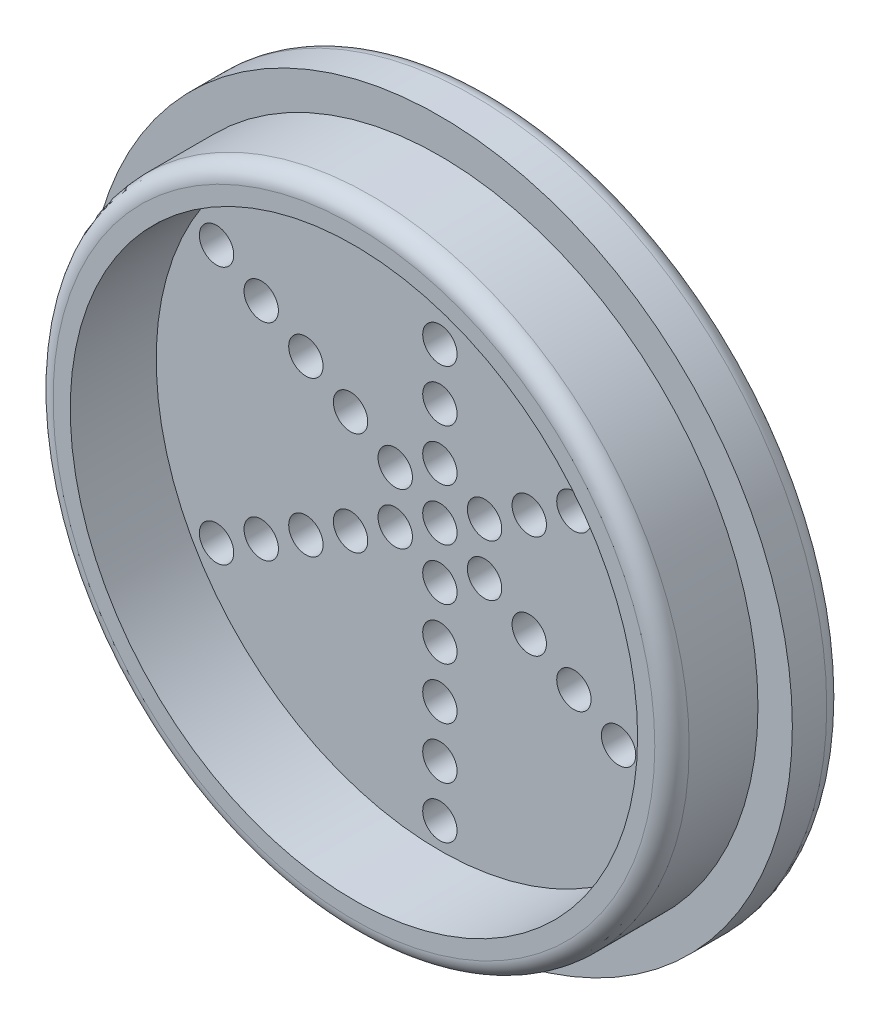
from build123d import *

# Parameters (mm, degrees)
SKETCH2_R                      = 20.5
BOSS_EXTRUDE1_DEPTH            = 3
SKETCH3_R                      = 18.5
BOSS_EXTRUDE2_DEPTH            = 5
SKETCH4_R                      = 16.5
CUT_EXTRUDE1_DEPTH             = 5
FILLET1_R                      = 1
FILLET2_R                      = 1
SKETCH9_R                      = 1
CUT_EXTRUDE2_DEPTH             = 3
F_2_0MM_DOWEL_HOLE4_AT_2_COUNT = 2
F_2_0MM_DOWEL_HOLE4_AT_2_PITCH = 3
F_2_0MM_DOWEL_HOLE4_AT_3_COUNT = 2
F_2_0MM_DOWEL_HOLE4_AT_3_PITCH = 6
F_2_0MM_DOWEL_HOLE4_AT_4_COUNT = 2
F_2_0MM_DOWEL_HOLE4_AT_4_PITCH = 9
F_2_0MM_DOWEL_HOLE4_AT_5_COUNT = 2
F_2_0MM_DOWEL_HOLE4_AT_5_PITCH = 12
CIRPATTERN1_COUNT              = 6


with BuildPart() as part:
    # Sketch2 → Boss-Extrude1 (new body)
    with BuildSketch(Plane.XY):
        Circle(SKETCH2_R)
    extrude(amount=BOSS_EXTRUDE1_DEPTH)

    # Sketch3 → Boss-Extrude2 (add)
    with BuildSketch(Plane.XY.offset(3)):
        Circle(SKETCH3_R)
    extrude(amount=BOSS_EXTRUDE2_DEPTH)

    # Sketch4 → Cut-Extrude1 (cut)
    with BuildSketch(Plane.XY.offset(8)):
        Circle(SKETCH4_R)
    extrude(amount=-CUT_EXTRUDE1_DEPTH, mode=Mode.SUBTRACT)

    # Fillet1
    fillet1_edges = [part.edges().sort_by_distance(p)[0] for p in [
        (-18.5, 0, 8),
    ]]
    fillet(fillet1_edges, radius=FILLET1_R)

    # Fillet2
    fillet2_edges = [part.edges().sort_by_distance(p)[0] for p in [
        (-20.5, 0, 0),
    ]]
    fillet(fillet2_edges, radius=FILLET2_R)

    # Sketch9 → Cut-Extrude2 (cut)
    with BuildSketch(Plane(origin=(0, 0, 0), x_dir=(-1, 0, 0), z_dir=(0, 0, -1))):
        Circle(SKETCH9_R)
    extrude(amount=-CUT_EXTRUDE2_DEPTH, mode=Mode.SUBTRACT)

    # Sketch12 → Ø2.0mm Dowel Hole4 (revolve, cut)
    with BuildSketch(Plane(origin=(0, 3, 0), x_dir=(0, 1, 0), z_dir=(1, 0, 0))):
        Polygon((0, 0), (0, 100.600860619), (1, 100), (1, 0), align=None)
    f_2_0mm_dowel_hole4 = revolve(axis=Axis((0, 3, -6.35), (0, 0, 1)), mode=Mode.SUBTRACT)

    # Ø2.0mm Dowel Hole4 at 2: Ø2.0mm Dowel Hole4 ×2
    with Locations(*[(0, i * F_2_0MM_DOWEL_HOLE4_AT_2_PITCH, 0) for i in range(1, F_2_0MM_DOWEL_HOLE4_AT_2_COUNT)]):
        add(f_2_0mm_dowel_hole4, mode=Mode.SUBTRACT)

    # Ø2.0mm Dowel Hole4 at 3: Ø2.0mm Dowel Hole4 ×2
    with Locations(*[(0, i * F_2_0MM_DOWEL_HOLE4_AT_3_PITCH, 0) for i in range(1, F_2_0MM_DOWEL_HOLE4_AT_3_COUNT)]):
        add(f_2_0mm_dowel_hole4, mode=Mode.SUBTRACT)

    # Ø2.0mm Dowel Hole4 at 4: Ø2.0mm Dowel Hole4 ×2
    with Locations(*[(0, i * F_2_0MM_DOWEL_HOLE4_AT_4_PITCH, 0) for i in range(1, F_2_0MM_DOWEL_HOLE4_AT_4_COUNT)]):
        add(f_2_0mm_dowel_hole4, mode=Mode.SUBTRACT)

    # Ø2.0mm Dowel Hole4 at 5: Ø2.0mm Dowel Hole4 ×2
    with Locations(*[(0, i * F_2_0MM_DOWEL_HOLE4_AT_5_PITCH, 0) for i in range(1, F_2_0MM_DOWEL_HOLE4_AT_5_COUNT)]):
        add(f_2_0mm_dowel_hole4, mode=Mode.SUBTRACT)

    # CirPattern1: Ø2.0mm Dowel Hole4 ×6 about axis
    cirpattern1_axis = Axis((0, 0, 0), (0, 0, 1))
    for i in range(1, CIRPATTERN1_COUNT):
        add(f_2_0mm_dowel_hole4.rotate(cirpattern1_axis, i * 360 / CIRPATTERN1_COUNT), mode=Mode.SUBTRACT)

    # CirPattern1 copy 1 sketch → CirPattern1 copy 1 (revolve, cut)
    with BuildSketch(Plane(origin=(-5.196152423, 3, 0), x_dir=(-0.866025404, 0.5, 0), z_dir=(0.5, 0.866025404, 0))):
        Polygon((0, 0), (0, 100.600860619), (1, 100), (1, 0), align=None)
    revolve(axis=Axis((-5.196152423, 3, -6.35), (0, 0, 1)), mode=Mode.SUBTRACT)

    # CirPattern1 copy 2 sketch → CirPattern1 copy 2 (revolve, cut)
    with BuildSketch(Plane(origin=(-5.196152423, -3, 0), x_dir=(-0.866025404, -0.5, 0), z_dir=(-0.5, 0.866025404, 0))):
        Polygon((0, 0), (0, 100.600860619), (1, 100), (1, 0), align=None)
    revolve(axis=Axis((-5.196152423, -3, -6.35), (0, 0, 1)), mode=Mode.SUBTRACT)

    # CirPattern1 copy 3 sketch → CirPattern1 copy 3 (revolve, cut)
    with BuildSketch(Plane(origin=(0, -6, 0), x_dir=(0, -1, 0), z_dir=(-1, 0, 0))):
        Polygon((0, 0), (0, 100.600860619), (1, 100), (1, 0), align=None)
    revolve(axis=Axis((0, -6, -6.35), (0, 0, 1)), mode=Mode.SUBTRACT)

    # CirPattern1 copy 4 sketch → CirPattern1 copy 4 (revolve, cut)
    with BuildSketch(Plane(origin=(5.196152423, -3, 0), x_dir=(0.866025404, -0.5, 0), z_dir=(-0.5, -0.866025404, 0))):
        Polygon((0, 0), (0, 100.600860619), (1, 100), (1, 0), align=None)
    revolve(axis=Axis((5.196152423, -3, -6.35), (0, 0, 1)), mode=Mode.SUBTRACT)

    # CirPattern1 copy 5 sketch → CirPattern1 copy 5 (revolve, cut)
    with BuildSketch(Plane(origin=(5.196152423, 3, 0), x_dir=(0.866025404, 0.5, 0), z_dir=(0.5, -0.866025404, 0))):
        Polygon((0, 0), (0, 100.600860619), (1, 100), (1, 0), align=None)
    revolve(axis=Axis((5.196152423, 3, -6.35), (0, 0, 1)), mode=Mode.SUBTRACT)

    # CirPattern1 copy 6 sketch → CirPattern1 copy 6 (revolve, cut)
    with BuildSketch(Plane(origin=(-7.794228634, 4.5, 0), x_dir=(-0.866025404, 0.5, 0), z_dir=(0.5, 0.866025404, 0))):
        Polygon((0, 0), (0, 100.600860619), (1, 100), (1, 0), align=None)
    revolve(axis=Axis((-7.794228634, 4.5, -6.35), (0, 0, 1)), mode=Mode.SUBTRACT)

    # CirPattern1 copy 7 sketch → CirPattern1 copy 7 (revolve, cut)
    with BuildSketch(Plane(origin=(-7.794228634, -4.5, 0), x_dir=(-0.866025404, -0.5, 0), z_dir=(-0.5, 0.866025404, 0))):
        Polygon((0, 0), (0, 100.600860619), (1, 100), (1, 0), align=None)
    revolve(axis=Axis((-7.794228634, -4.5, -6.35), (0, 0, 1)), mode=Mode.SUBTRACT)

    # CirPattern1 copy 8 sketch → CirPattern1 copy 8 (revolve, cut)
    with BuildSketch(Plane(origin=(0, -9, 0), x_dir=(0, -1, 0), z_dir=(-1, 0, 0))):
        Polygon((0, 0), (0, 100.600860619), (1, 100), (1, 0), align=None)
    revolve(axis=Axis((0, -9, -6.35), (0, 0, 1)), mode=Mode.SUBTRACT)

    # CirPattern1 copy 9 sketch → CirPattern1 copy 9 (revolve, cut)
    with BuildSketch(Plane(origin=(7.794228634, -4.5, 0), x_dir=(0.866025404, -0.5, 0), z_dir=(-0.5, -0.866025404, 0))):
        Polygon((0, 0), (0, 100.600860619), (1, 100), (1, 0), align=None)
    revolve(axis=Axis((7.794228634, -4.5, -6.35), (0, 0, 1)), mode=Mode.SUBTRACT)

    # CirPattern1 copy 10 sketch → CirPattern1 copy 10 (revolve, cut)
    with BuildSketch(Plane(origin=(7.794228634, 4.5, 0), x_dir=(0.866025404, 0.5, 0), z_dir=(0.5, -0.866025404, 0))):
        Polygon((0, 0), (0, 100.600860619), (1, 100), (1, 0), align=None)
    revolve(axis=Axis((7.794228634, 4.5, -6.35), (0, 0, 1)), mode=Mode.SUBTRACT)

    # CirPattern1 copy 11 sketch → CirPattern1 copy 11 (revolve, cut)
    with BuildSketch(Plane(origin=(-10.392304845, 6, 0), x_dir=(-0.866025404, 0.5, 0), z_dir=(0.5, 0.866025404, 0))):
        Polygon((0, 0), (0, 100.600860619), (1, 100), (1, 0), align=None)
    revolve(axis=Axis((-10.392304845, 6, -6.35), (0, 0, 1)), mode=Mode.SUBTRACT)

    # CirPattern1 copy 12 sketch → CirPattern1 copy 12 (revolve, cut)
    with BuildSketch(Plane(origin=(-10.392304845, -6, 0), x_dir=(-0.866025404, -0.5, 0), z_dir=(-0.5, 0.866025404, 0))):
        Polygon((0, 0), (0, 100.600860619), (1, 100), (1, 0), align=None)
    revolve(axis=Axis((-10.392304845, -6, -6.35), (0, 0, 1)), mode=Mode.SUBTRACT)

    # CirPattern1 copy 13 sketch → CirPattern1 copy 13 (revolve, cut)
    with BuildSketch(Plane(origin=(0, -12, 0), x_dir=(0, -1, 0), z_dir=(-1, 0, 0))):
        Polygon((0, 0), (0, 100.600860619), (1, 100), (1, 0), align=None)
    revolve(axis=Axis((0, -12, -6.35), (0, 0, 1)), mode=Mode.SUBTRACT)

    # CirPattern1 copy 14 sketch → CirPattern1 copy 14 (revolve, cut)
    with BuildSketch(Plane(origin=(10.392304845, -6, 0), x_dir=(0.866025404, -0.5, 0), z_dir=(-0.5, -0.866025404, 0))):
        Polygon((0, 0), (0, 100.600860619), (1, 100), (1, 0), align=None)
    revolve(axis=Axis((10.392304845, -6, -6.35), (0, 0, 1)), mode=Mode.SUBTRACT)

    # CirPattern1 copy 15 sketch → CirPattern1 copy 15 (revolve, cut)
    with BuildSketch(Plane(origin=(10.392304845, 6, 0), x_dir=(0.866025404, 0.5, 0), z_dir=(0.5, -0.866025404, 0))):
        Polygon((0, 0), (0, 100.600860619), (1, 100), (1, 0), align=None)
    revolve(axis=Axis((10.392304845, 6, -6.35), (0, 0, 1)), mode=Mode.SUBTRACT)

    # CirPattern1 copy 16 sketch → CirPattern1 copy 16 (revolve, cut)
    with BuildSketch(Plane(origin=(-12.990381057, 7.5, 0), x_dir=(-0.866025404, 0.5, 0), z_dir=(0.5, 0.866025404, 0))):
        Polygon((0, 0), (0, 100.600860619), (1, 100), (1, 0), align=None)
    revolve(axis=Axis((-12.990381057, 7.5, -6.35), (0, 0, 1)), mode=Mode.SUBTRACT)

    # CirPattern1 copy 17 sketch → CirPattern1 copy 17 (revolve, cut)
    with BuildSketch(Plane(origin=(-12.990381057, -7.5, 0), x_dir=(-0.866025404, -0.5, 0), z_dir=(-0.5, 0.866025404, 0))):
        Polygon((0, 0), (0, 100.600860619), (1, 100), (1, 0), align=None)
    revolve(axis=Axis((-12.990381057, -7.5, -6.35), (0, 0, 1)), mode=Mode.SUBTRACT)

    # CirPattern1 copy 18 sketch → CirPattern1 copy 18 (revolve, cut)
    with BuildSketch(Plane(origin=(0, -15, 0), x_dir=(0, -1, 0), z_dir=(-1, 0, 0))):
        Polygon((0, 0), (0, 100.600860619), (1, 100), (1, 0), align=None)
    revolve(axis=Axis((0, -15, -6.35), (0, 0, 1)), mode=Mode.SUBTRACT)

    # CirPattern1 copy 19 sketch → CirPattern1 copy 19 (revolve, cut)
    with BuildSketch(Plane(origin=(12.990381057, -7.5, 0), x_dir=(0.866025404, -0.5, 0), z_dir=(-0.5, -0.866025404, 0))):
        Polygon((0, 0), (0, 100.600860619), (1, 100), (1, 0), align=None)
    revolve(axis=Axis((12.990381057, -7.5, -6.35), (0, 0, 1)), mode=Mode.SUBTRACT)

    # CirPattern1 copy 20 sketch → CirPattern1 copy 20 (revolve, cut)
    with BuildSketch(Plane(origin=(12.990381057, 7.5, 0), x_dir=(0.866025404, 0.5, 0), z_dir=(0.5, -0.866025404, 0))):
        Polygon((0, 0), (0, 100.600860619), (1, 100), (1, 0), align=None)
    revolve(axis=Axis((12.990381057, 7.5, -6.35), (0, 0, 1)), mode=Mode.SUBTRACT)


solid = part.part
